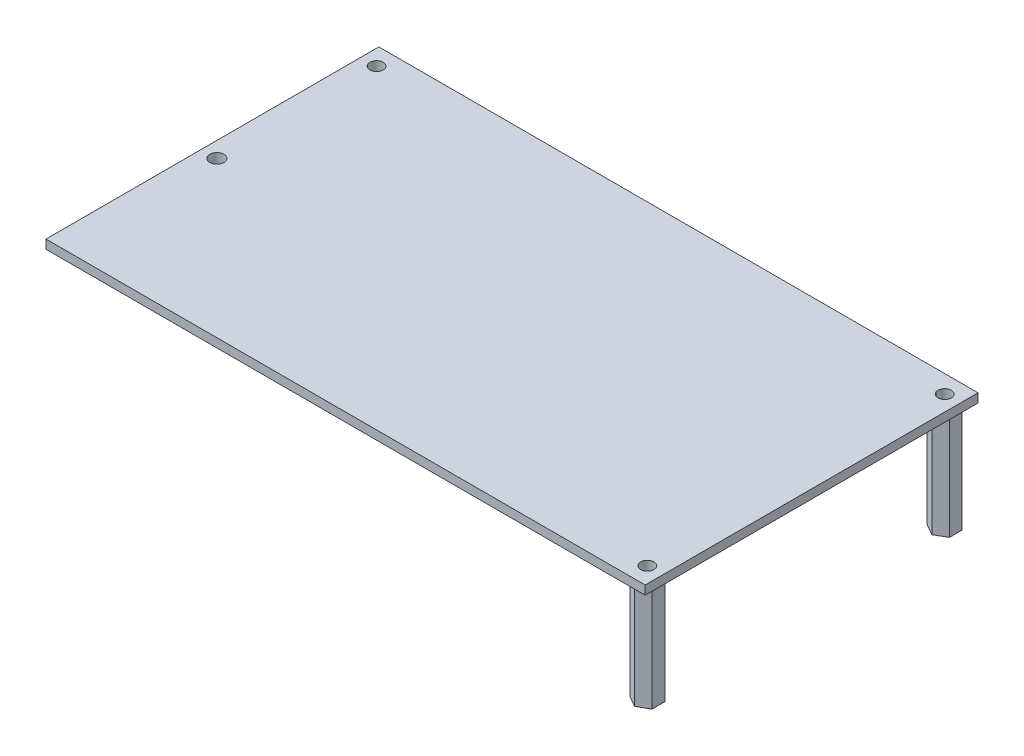
from build123d import *

# Parameters (mm, degrees)
SKETCH_1_W          = 135
SKETCH_1_H          = 75
SKETCH_1_R          = 1.5
SKETCH_1_R_2        = 1.6
EXTRUDE_1_DEPTH     = 2
EXTRUDE_2_DEPTH     = 24
SKETCH_3_R          = 1.5
SKETCH_3_R_2        = 1.6
CUT_EXTRUDE_1_DEPTH = 25


with BuildPart() as part:
    # Эскиз1 → Бобышка-Вытянуть1 (new body)
    with BuildSketch(Plane(origin=(0, 0, 0), x_dir=(1, 0, 0), z_dir=(0, 1, 0))):
        with Locations((67.5, 37.5)):
            Rectangle(SKETCH_1_W, SKETCH_1_H)
        with Locations((3.5, 71)):
            Circle(SKETCH_1_R, mode=Mode.SUBTRACT)
        with Locations((3.5, 35)):
            Circle(SKETCH_1_R_2, mode=Mode.SUBTRACT)
        with Locations((131.5, 71)):
            Circle(SKETCH_1_R, mode=Mode.SUBTRACT)
        with Locations((131.5, 4)):
            Circle(SKETCH_1_R, mode=Mode.SUBTRACT)
    extrude(amount=EXTRUDE_1_DEPTH)

    # Эскиз2 → Бобышка-Вытянуть2 (add)
    with BuildSketch(Plane.XZ):
        Polygon((3.5, -37.886751346), (6, -36.443375673), (6, -33.556624327), (3.5, -32.113248654), (1, -33.556624327), (1, -36.443375673), align=None)
        Polygon((3.5, -73.886751346), (6, -72.443375673), (6, -69.556624327), (3.5, -68.113248654), (1, -69.556624327), (1, -72.443375673), align=None)
        Polygon((131.5, -6.886751346), (134, -5.443375673), (134, -2.556624327), (131.5, -1.113248654), (129, -2.556624327), (129, -5.443375673), align=None)
        Polygon((129, -72.443375673), (131.5, -73.886751346), (134, -72.443375673), (134, -69.556624327), (131.5, -68.113248654), (129, -69.556624327), align=None)
    extrude(amount=EXTRUDE_2_DEPTH)

    # Эскиз3 → Вырез-Вытянуть1 (cut, through all)
    with BuildSketch(Plane(origin=(0, 0, 0), x_dir=(1, 0, 0), z_dir=(0, 1, 0))):
        with Locations((3.5, 71)):
            Circle(SKETCH_3_R)
        with Locations((131.5, 4)):
            Circle(SKETCH_3_R)
        with Locations((131.5, 71)):
            Circle(SKETCH_3_R)
        with Locations((3.5, 35)):
            Circle(SKETCH_3_R_2)
    extrude(amount=-CUT_EXTRUDE_1_DEPTH, mode=Mode.SUBTRACT)


solid = part.part
